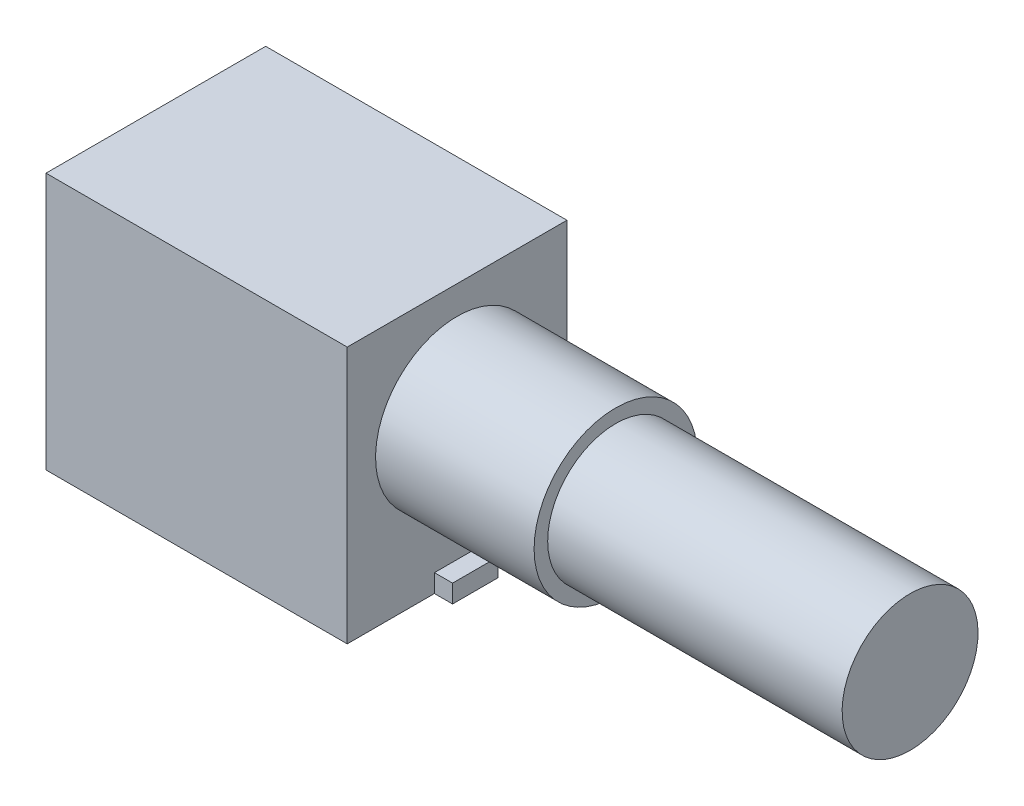
from build123d import *

# Parameters (mm, degrees)
SKETCH1_W           = 13.3
SKETCH1_H           = 11.35
BOSS_EXTRUDE1_DEPTH = 9.7
SKETCH2_R           = 3.6
BOSS_EXTRUDE2_DEPTH = 7
SKETCH3_R           = 3
BOSS_EXTRUDE4_DEPTH = 13
SKETCH4_W           = 2
SKETCH4_H           = 0.8
BOSS_EXTRUDE5_DEPTH = 0.8


with BuildPart() as part:
    # Sketch1 → Boss-Extrude1 (new body)
    with BuildSketch(Plane.XY):
        with Locations((6.65, 5.675)):
            Rectangle(SKETCH1_W, SKETCH1_H)
    extrude(amount=BOSS_EXTRUDE1_DEPTH)

    # Sketch2 → Boss-Extrude2 (add)
    with BuildSketch(Plane(origin=(13.3, 0, 0), x_dir=(0, 0, -1), z_dir=(1, 0, 0))):
        with Locations(Location((-4.85, 6.5, 0), (0, 0, 270))):  # turned: the seam where the file's is
            Circle(SKETCH2_R)
    extrude(amount=BOSS_EXTRUDE2_DEPTH)

    # Sketch3 → Boss-Extrude4 (add)
    with BuildSketch(Plane(origin=(20.3, 0, 0), x_dir=(0, 0, -1), z_dir=(1, 0, 0))):
        with Locations(Location((-4.85, 6.5, 0), (0, 0, 270))):  # turned: the seam where the file's is
            Circle(SKETCH3_R)
    extrude(amount=BOSS_EXTRUDE4_DEPTH)

    # Sketch4 → Boss-Extrude5 (add)
    with BuildSketch(Plane(origin=(13.3, 0, 0), x_dir=(0, 0, -1), z_dir=(1, 0, 0))):
        with Locations((-4.85, 0.4)):
            Rectangle(SKETCH4_W, SKETCH4_H)
    extrude(amount=BOSS_EXTRUDE5_DEPTH)


solid = part.part
